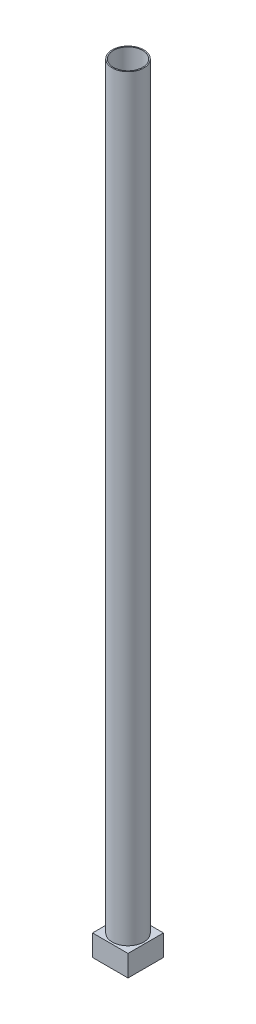
from build123d import *

# Parameters (mm, degrees)
SKETCH1_W           = 100
SKETCH1_H           = 100
BOSS_EXTRUDE1_DEPTH = 30
SKETCH2_R           = 44.45
SKETCH2_R_2         = 41.275
BOSS_EXTRUDE2_DEPTH = 2133.6


with BuildPart() as part:
    # Sketch1 → Boss-Extrude1 (new body, symmetric)
    with BuildSketch(Plane(origin=(0, 0, 0), x_dir=(1, 0, 0), z_dir=(0, 1, 0))):
        Rectangle(SKETCH1_W, SKETCH1_H)
    extrude(amount=BOSS_EXTRUDE1_DEPTH, both=True)

    # Sketch2 → Boss-Extrude2 (add)
    with BuildSketch(Plane(origin=(0, 30, 0), x_dir=(1, 0, 0), z_dir=(0, 1, 0))):
        Circle(SKETCH2_R)
        Circle(SKETCH2_R_2, mode=Mode.SUBTRACT)
    extrude(amount=BOSS_EXTRUDE2_DEPTH)


solid = part.part
